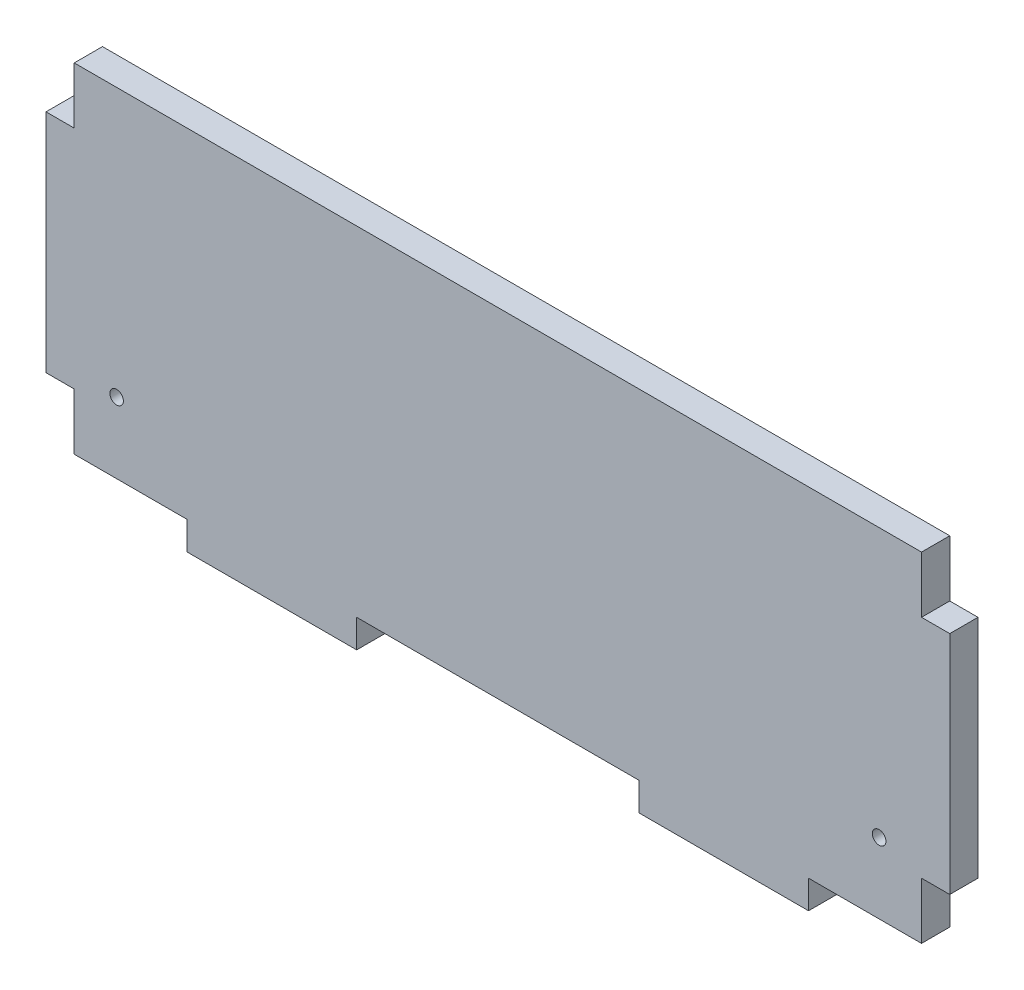
from build123d import *

# Parameters (mm, degrees)
SKETCH1_W           = 190.5
SKETCH1_H           = 76.2
BOSS_EXTRUDE1_DEPTH = 6.35
SKETCH2_W           = 6.35
SKETCH2_H           = 50.8
BOSS_EXTRUDE2_DEPTH = 6.35
SKETCH3_W           = 6.35
SKETCH3_H           = 50.8
BOSS_EXTRUDE3_DEPTH = 6.35
SKETCH4_W           = 38.1
SKETCH4_H           = 6.35
BOSS_EXTRUDE4_DEPTH = 6.35
SKETCH6_R           = 1.524
CUT_EXTRUDE4_DEPTH  = 6.35


with BuildPart() as part:
    # Sketch1 → Boss-Extrude1 (new body)
    with BuildSketch(Plane.XY):
        Rectangle(SKETCH1_W, SKETCH1_H)
    extrude(amount=BOSS_EXTRUDE1_DEPTH)

    # Sketch2 → Boss-Extrude2 (add)
    with BuildSketch(Plane.ZY.offset(95.25)):
        with Locations((3.175, 0)):
            Rectangle(SKETCH2_W, SKETCH2_H)
    extrude(amount=BOSS_EXTRUDE2_DEPTH)

    # Sketch3 → Boss-Extrude3 (add)
    with BuildSketch(Plane(origin=(95.25, 0, 0), x_dir=(0, 0, -1), z_dir=(1, 0, 0))):
        with Locations((-3.175, 0)):
            Rectangle(SKETCH3_W, SKETCH3_H)
    extrude(amount=BOSS_EXTRUDE3_DEPTH)

    # Sketch4 → Boss-Extrude4 (add)
    with BuildSketch(Plane.XZ.offset(38.1)):
        with Locations((-50.8, 3.175)):
            Rectangle(SKETCH4_W, SKETCH4_H)
        with Locations((50.8, 3.175)):
            Rectangle(SKETCH4_W, SKETCH4_H)
    extrude(amount=BOSS_EXTRUDE4_DEPTH)

    # Sketch6 → Cut-Extrude4 (cut)
    with BuildSketch(Plane(origin=(23.763692911, 98.5857123, 0), x_dir=(-1, 0, 0), z_dir=(0, 0, -1))):
        with Locations((-61.961307089, -120.8107123)):
            Circle(SKETCH6_R)
        with Locations((109.488692911, -120.8107123)):
            Circle(SKETCH6_R)
    extrude(amount=-CUT_EXTRUDE4_DEPTH, mode=Mode.SUBTRACT)


solid = part.part
